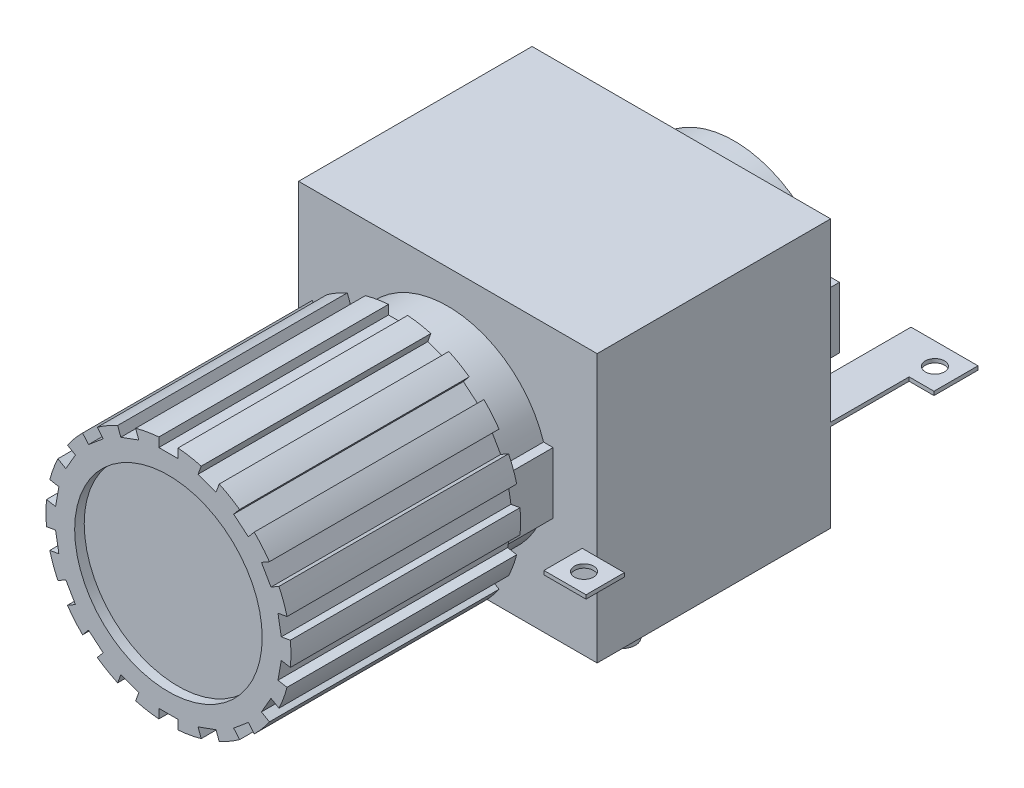
from build123d import *

# Parameters (mm, degrees)
CROQUIS1_R              = 32
SALIENTE_EXTRUIR1_DEPTH = 60
CROQUIS2_R              = 24.5
CORTAR_EXTRUIR1_DEPTH   = 2.5
CROQUIS3_W              = 5
CROQUIS3_H              = 5
CORTAR_EXTRUIR2_DEPTH   = 61
MATRIZC1_COUNT          = 18
CROQUIS4_R              = 26.25
SALIENTE_EXTRUIR2_DEPTH = 87.8
CROQUIS5_R              = 22.75
CORTAR_EXTRUIR3_DEPTH   = 37
SALIENTE_EXTRUIR3_REACH = 149.8
CROQUIS6_W              = 2.5
CROQUIS6_H              = 16
CROQUIS7_W              = 78
CROQUIS7_H              = 70
SALIENTE_EXTRUIR4_DEPTH = 61
CROQUIS8_W              = 10
CROQUIS8_H              = 1
SALIENTE_EXTRUIR5_DEPTH = 11.5
CROQUIS9_W              = 10
CROQUIS9_H              = 13
SALIENTE_EXTRUIR6_DEPTH = 1
CROQUIS10_W             = 11
CROQUIS10_H             = 10
SALIENTE_EXTRUIR7_DEPTH = 1
SALIENTE_EXTRUIR8_DEPTH = 1
CROQUIS12_R             = 2.5
CORTAR_EXTRUIR4_DEPTH   = 29
CROQUIS13_R             = 2.5
CORTAR_EXTRUIR5_DEPTH   = 1
CROQUIS14_R             = 2.5
CORTAR_EXTRUIR6_DEPTH   = 1
CROQUIS15_R             = 2.5
CORTAR_EXTRUIR7_DEPTH   = 1
CROQUIS16_R             = 3.5
SALIENTE_EXTRUIR9_DEPTH = 10


with BuildPart() as part:
    # Croquis1 → Saliente-Extruir1 (new body)
    with BuildSketch(Plane.XY):
        Circle(CROQUIS1_R)
    extrude(amount=SALIENTE_EXTRUIR1_DEPTH)

    # Croquis2 → Cortar-Extruir1 (cut)
    with BuildSketch(Plane.XY.offset(60)):
        Circle(CROQUIS2_R)
    extrude(amount=-CORTAR_EXTRUIR1_DEPTH, mode=Mode.SUBTRACT)

    # Croquis3 → Cortar-Extruir2 (cut, through all)
    with BuildSketch(Plane.XY.offset(60)):
        with Locations((0, 32)):
            Rectangle(CROQUIS3_W, CROQUIS3_H)
    cortar_extruir2 = extrude(amount=-CORTAR_EXTRUIR2_DEPTH, mode=Mode.SUBTRACT)

    # MatrizC1: Cortar-Extruir2 ×18 about axis
    matrizc1_axis = Axis((0, 0, 0), (0, 0, 1))
    for i in range(1, MATRIZC1_COUNT):
        add(cortar_extruir2.rotate(matrizc1_axis, i * 360 / MATRIZC1_COUNT), mode=Mode.SUBTRACT)

    # Croquis4 → Saliente-Extruir2 (add)
    with BuildSketch(Plane(origin=(0, 0, 0), x_dir=(-1, 0, 0), z_dir=(0, 0, -1))):
        Circle(CROQUIS4_R)
    extrude(amount=SALIENTE_EXTRUIR2_DEPTH)

    # Croquis5 → Cortar-Extruir3 (cut)
    with BuildSketch(Plane(origin=(0, 0, -87.8), x_dir=(-1, 0, 0), z_dir=(0, 0, -1))):
        Circle(CROQUIS5_R)
    extrude(amount=-CORTAR_EXTRUIR3_DEPTH, mode=Mode.SUBTRACT)

    # Croquis6 → Saliente-Extruir3 (add, up to next)
    with BuildSketch(Plane(origin=(0, 0, -87.8), x_dir=(-1, 0, 0), z_dir=(0, 0, -1)), mode=Mode.PRIVATE) as saliente_extruir3_sk1:
        with Locations((-26.25, 0)):
            Rectangle(CROQUIS6_W, CROQUIS6_H)
    saliente_extruir3_tool1 = extrude(saliente_extruir3_sk1.sketch, amount=-SALIENTE_EXTRUIR3_REACH, mode=Mode.PRIVATE) - part.part
    add(saliente_extruir3_tool1.solids().sort_by_distance((26.25, 0, -87.8))[0])

    # Croquis7 → Saliente-Extruir4 (add)
    with BuildSketch(Plane(origin=(0, 0, -13), x_dir=(-1, 0, 0), z_dir=(0, 0, -1))):
        Rectangle(CROQUIS7_W, CROQUIS7_H)
    extrude(amount=SALIENTE_EXTRUIR4_DEPTH)

    # Croquis8 → Saliente-Extruir5 (add)
    with BuildSketch(Plane.ZY.offset(39)):
        with Locations((-64.8, -11.5)):
            Rectangle(CROQUIS8_W, CROQUIS8_H)
        with Locations((-8, -7.5)):
            Rectangle(CROQUIS8_W, CROQUIS8_H)
    extrude(amount=SALIENTE_EXTRUIR5_DEPTH)

    # Croquis9 → Saliente-Extruir6 (add)
    with BuildSketch(Plane.ZY.offset(39)):
        with Locations((-8, -1.5)):
            Rectangle(CROQUIS9_W, CROQUIS9_H)
    extrude(amount=-SALIENTE_EXTRUIR6_DEPTH)

    # Croquis10 → Saliente-Extruir7 (add)
    with BuildSketch(Plane(origin=(0, -11, 0), x_dir=(-1, 0, 0), z_dir=(0, -1, 0))):
        with Locations((-40.6, 8)):
            Rectangle(CROQUIS10_W, CROQUIS10_H)
    extrude(amount=SALIENTE_EXTRUIR7_DEPTH)

    # Croquis11 → Saliente-Extruir8 (add)
    with BuildSketch(Plane(origin=(0, -11, 0), x_dir=(-1, 0, 0), z_dir=(0, -1, 0))):
        Polygon((-39, 74), (-28, 74), (-28, 106), (-45.5, 106), (-45.5, 94.5), (-39, 94.5), align=None)
    extrude(amount=SALIENTE_EXTRUIR8_DEPTH)

    # Croquis12 → Cortar-Extruir4 (cut, through all)
    with BuildSketch(Plane(origin=(0, -7, 0), x_dir=(1, 0, 0), z_dir=(0, 1, 0))):
        with Locations((-44.75, 7.949105166)):
            Circle(CROQUIS12_R)
    extrude(amount=-CORTAR_EXTRUIR4_DEPTH, mode=Mode.SUBTRACT)

    # Croquis13 → Cortar-Extruir5 (cut)
    with BuildSketch(Plane(origin=(0, -11, 0), x_dir=(1, 0, 0), z_dir=(0, 1, 0))):
        with Locations((40.6, 7.978589127)):
            Circle(CROQUIS13_R)
    extrude(amount=-CORTAR_EXTRUIR5_DEPTH, mode=Mode.SUBTRACT)

    # Croquis14 → Cortar-Extruir6 (cut)
    with BuildSketch(Plane(origin=(0, -11, 0), x_dir=(1, 0, 0), z_dir=(0, 1, 0))):
        with Locations((-44.75, 65.049509944)):
            Circle(CROQUIS14_R)
    extrude(amount=-CORTAR_EXTRUIR6_DEPTH, mode=Mode.SUBTRACT)

    # Croquis15 → Cortar-Extruir7 (cut)
    with BuildSketch(Plane(origin=(0, -11, 0), x_dir=(1, 0, 0), z_dir=(0, 1, 0))):
        with Locations((40, 100.25)):
            Circle(CROQUIS15_R)
    extrude(amount=-CORTAR_EXTRUIR7_DEPTH, mode=Mode.SUBTRACT)

    # Croquis16 → Saliente-Extruir9 (add)
    with BuildSketch(Plane(origin=(0, -35, 0), x_dir=(-1, 0, 0), z_dir=(0, -1, 0))):
        with Locations((-26.5, 32)):
            Circle(CROQUIS16_R)
    extrude(amount=SALIENTE_EXTRUIR9_DEPTH)


solid = part.part
